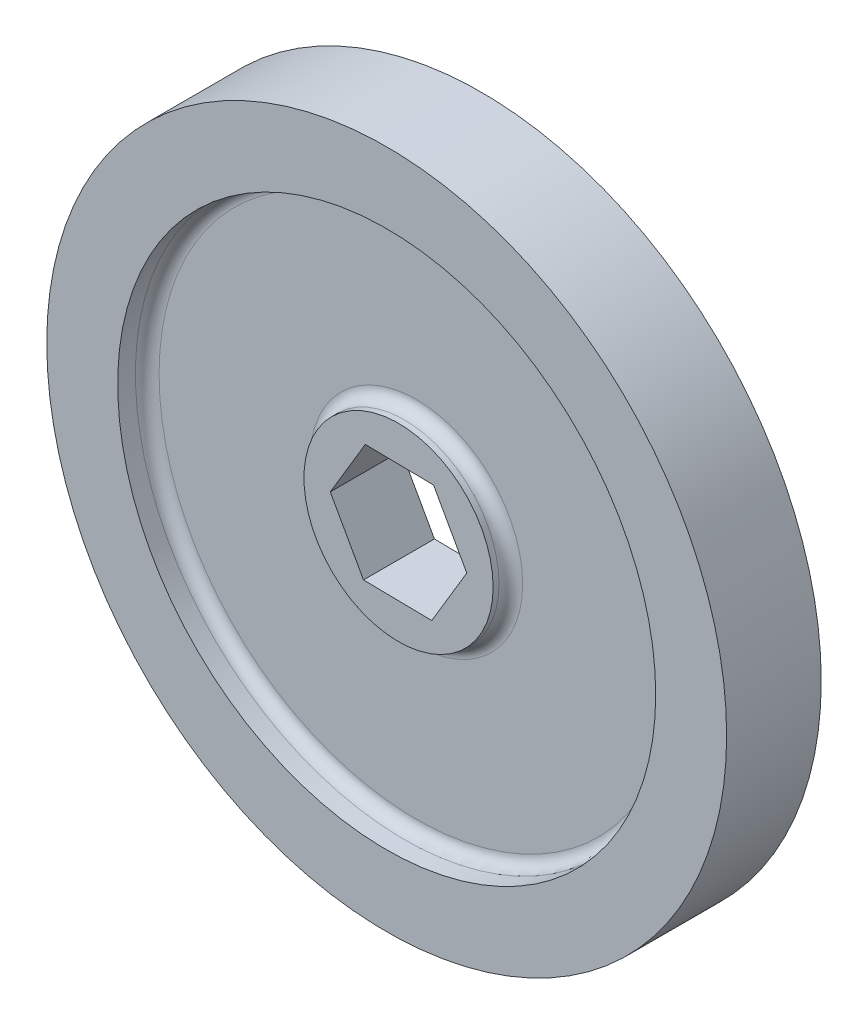
from build123d import *

# Parameters (mm, degrees)
SKETCH1_R           = 36.5125
BOSS_EXTRUDE1_DEPTH = 10.16
SKETCH2_R           = 28.8925
SKETCH2_R_2         = 10.16
CUT_EXTRUDE1_DEPTH  = 3.175
SKETCH3_R           = 28.8925
SKETCH3_R_2         = 10.16
CUT_EXTRUDE2_DEPTH  = 3.175
SKETCH4_R           = 10.16
CUT_EXTRUDE3_DEPTH  = 1.27
SKETCH7_R           = 10.16
CUT_EXTRUDE5_DEPTH  = 1.27
FILLET1_R           = 1.27


with BuildPart() as part:
    # Sketch1 → Boss-Extrude1 (new body)
    with BuildSketch(Plane.XY):
        Circle(SKETCH1_R)
        Polygon((3.569234353, -6.4049902), (7.331501401, -0.111447478), (3.762267048, 6.293542722), (-3.569234353, 6.4049902), (-7.331501401, 0.111447478), (-3.762267048, -6.293542722), align=None, mode=Mode.SUBTRACT)
    extrude(amount=BOSS_EXTRUDE1_DEPTH)

    # Sketch2 → Cut-Extrude1 (cut)
    with BuildSketch(Plane.XY.offset(10.16)):
        Circle(SKETCH2_R)
        Circle(SKETCH2_R_2, mode=Mode.SUBTRACT)
    extrude(amount=-CUT_EXTRUDE1_DEPTH, mode=Mode.SUBTRACT)

    # Sketch3 → Cut-Extrude2 (cut)
    with BuildSketch(Plane(origin=(0, 0, 0), x_dir=(-1, 0, 0), z_dir=(0, 0, -1))):
        Circle(SKETCH3_R)
        Circle(SKETCH3_R_2, mode=Mode.SUBTRACT)
    extrude(amount=-CUT_EXTRUDE2_DEPTH, mode=Mode.SUBTRACT)

    # Sketch4 → Cut-Extrude3 (cut)
    with BuildSketch(Plane(origin=(0, 0, 0), x_dir=(-1, 0, 0), z_dir=(0, 0, -1))):
        Circle(SKETCH4_R)
    extrude(amount=-CUT_EXTRUDE3_DEPTH, mode=Mode.SUBTRACT)

    # Sketch7 → Cut-Extrude5 (cut)
    with BuildSketch(Plane.XY.offset(10.16)):
        Circle(SKETCH7_R)
    extrude(amount=-CUT_EXTRUDE5_DEPTH, mode=Mode.SUBTRACT)

    # Fillet1
    fillet1_edges = [part.edges().sort_by_distance(p)[0] for p in [
        (-28.8925, 0, 6.985),
        (-10.16, 0, 6.985),
        (28.8925, 0, 3.175),
        (10.16, 0, 3.175),
    ]]
    fillet(fillet1_edges, radius=FILLET1_R)


solid = part.part
